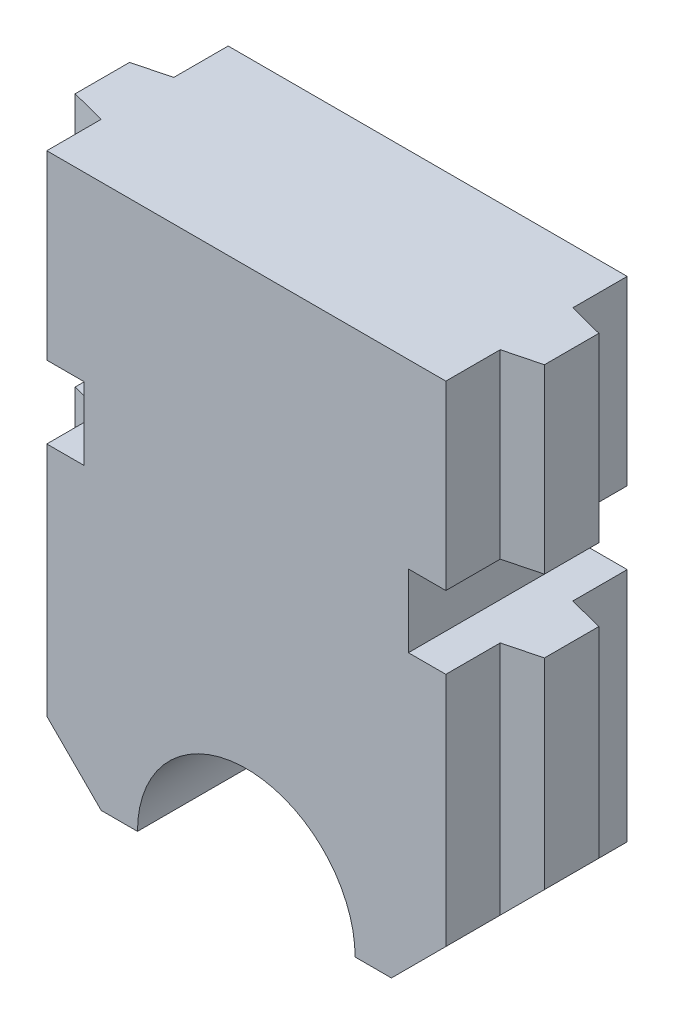
from build123d import *

# Parameters (mm, degrees)
BOSS_EXTRUDE1_DEPTH = 5
BOSS_EXTRUDE2_DEPTH = 15
CUT_EXTRUDE1_DEPTH  = 15
SKETCH4_W           = 2
SKETCH4_H           = 2
CUT_EXTRUDE2_DEPTH  = 15


with BuildPart() as part:
    # Sketch1 → Boss-Extrude1 (new body)
    with BuildSketch(Plane.XY):
        with BuildLine():
            Line((-19.818415432, 19.704812021), (-8.818415432, 19.704812021))
            Line((-8.818415432, 19.704812021), (-8.818415432, 6.204812021))
            Line((-8.818415432, 6.204812021), (-10.318415432, 4.704812021))
            Line((-10.318415432, 4.704812021), (-11.318415432, 4.704812021))
            ThreePointArc((-11.318415432, 4.704812021), (-14.318415432, 7.704812021), (-17.318415432, 4.704812021))
            Line((-17.318415432, 4.704812021), (-18.318415432, 4.704812021))
            Line((-18.318415432, 4.704812021), (-19.818415432, 6.204812021))
            Line((-19.818415432, 6.204812021), (-19.818415432, 19.704812021))
        make_face()
    extrude(amount=BOSS_EXTRUDE1_DEPTH)

    # Sketch2 → Boss-Extrude2 (add)
    with BuildSketch(Plane(origin=(0, 19.704812021, 0), x_dir=(1, 0, 0), z_dir=(0, 1, 0))):
        Polygon((-19.818415432, -1.5), (-8.818415432, -1.5), (-7.850169596, -1.75), (-7.850169596, -3.25), (-8.818415432, -3.5), (-19.818415432, -3.5), (-20.786661269, -3.25), (-20.786661269, -1.75), align=None)
    extrude(amount=-BOSS_EXTRUDE2_DEPTH)

    # Sketch3 → Cut-Extrude1 (cut)
    with BuildSketch(Plane.XY.offset(5)):
        with BuildLine():
            Line((-18.318415432, 4.704812021), (-20.786661269, 7.173057858))
            Line((-20.786661269, 7.173057858), (-20.786661269, 3.709596772))
            Line((-20.786661269, 3.709596772), (-7.850169596, 3.709596772))
            Line((-7.850169596, 3.709596772), (-7.850169596, 7.173057858))
            Line((-7.850169596, 7.173057858), (-10.318415432, 4.704812021))
            Line((-10.318415432, 4.704812021), (-11.318415432, 4.704812021))
            ThreePointArc((-11.318415432, 4.704812021), (-14.318415432, 7.704812021), (-17.318415432, 4.704812021))
            Line((-17.318415432, 4.704812021), (-18.318415432, 4.704812021))
        make_face()
    extrude(amount=-CUT_EXTRUDE1_DEPTH, mode=Mode.SUBTRACT)

    # Sketch4 → Cut-Extrude2 (cut)
    with BuildSketch(Plane.XY.offset(5)):
        with Locations((-19.786661269, 13.704812021)):
            Rectangle(SKETCH4_W, SKETCH4_H)
    cut_extrude2 = extrude(amount=-CUT_EXTRUDE2_DEPTH, mode=Mode.SUBTRACT)

    # Mirror1: Cut-Extrude2 across plane
    add(cut_extrude2.mirror(Plane(origin=(-14.318415432, 0, 0), x_dir=(0, 0, 1), z_dir=(1, 0, 0))), mode=Mode.SUBTRACT)


solid = part.part
